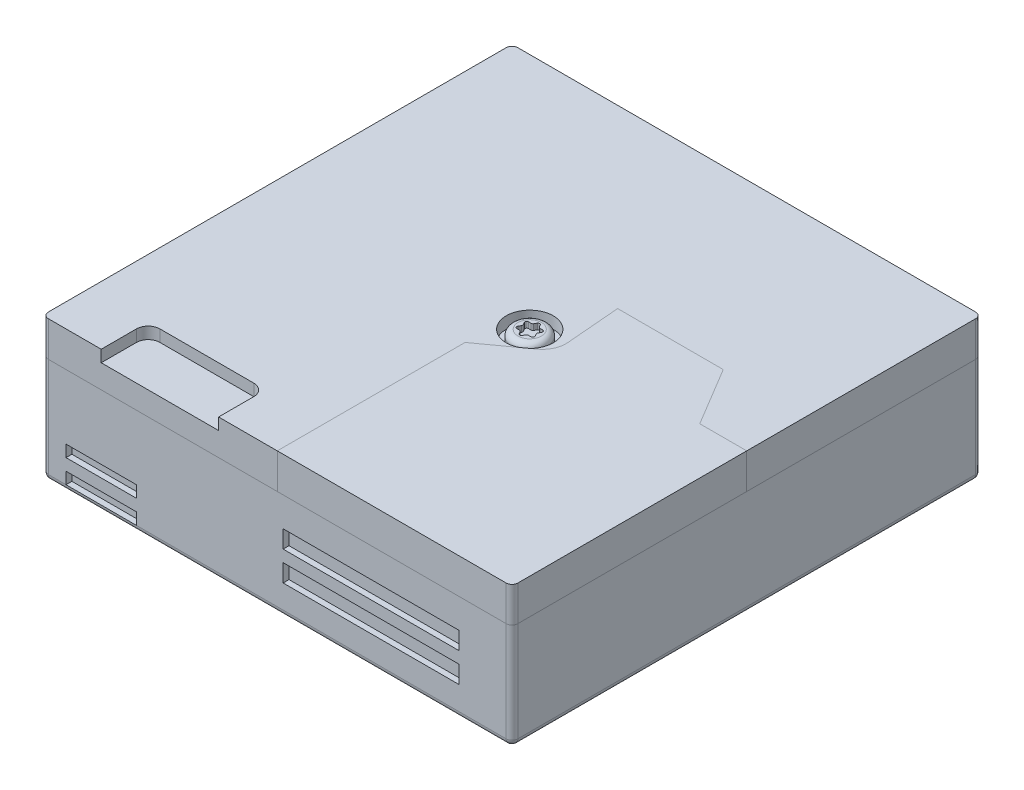
from build123d import *

# Parameters (mm, degrees)
SKETCH1_W           = 40
SKETCH1_H           = 40
BOSS_EXTRUDE1_DEPTH = 9
SKETCH1_2_W         = 40
SKETCH1_2_H         = 40
BOSS_EXTRUDE2_DEPTH = 3
SKETCH2_W           = 10
SKETCH2_H           = 4
CUT_EXTRUDE1_DEPTH  = 4
CUT_EXTRUDE3_DEPTH  = 3
BOSS_EXTRUDE4_DEPTH = 3
SKETCH4_R           = 2
CUT_EXTRUDE4_DEPTH  = 1
SKETCH5_R           = 1.5
BOSS_EXTRUDE6_DEPTH = 1
BOSS_EXTRUDE7_DEPTH = 0.5
FILLET1_R           = 0.5
FILLET2_R           = 0.5
FILLET3_R           = 0.5
FILLET4_R           = 0.5
SKETCH6_W           = 6
SKETCH6_H           = 1
SKETCH6_W_2         = 15
SKETCH6_H_2         = 1.5
CUT_EXTRUDE5_DEPTH  = 0.5


with BuildPart() as part:
    # Sketch1 → Boss-Extrude1 (new body)
    with BuildSketch(Plane(origin=(0, 0, 0), x_dir=(1, 0, 0), z_dir=(0, 1, 0))):
        with Locations((20, 20)):
            Rectangle(SKETCH1_W, SKETCH1_H)
    extrude(amount=-BOSS_EXTRUDE1_DEPTH)

    # Sketch2 → Cut-Extrude1 (cut)
    with BuildSketch(Plane(origin=(0, 0, -40), x_dir=(-1, 0, 0), z_dir=(0, 0, -1))):
        with Locations((-33, -4)):
            Rectangle(SKETCH2_W, SKETCH2_H)
    extrude(amount=-CUT_EXTRUDE1_DEPTH, mode=Mode.SUBTRACT)

    # Fillet3
    fillet3_edges = [part.edges().sort_by_distance(p)[0] for p in [
        (20, -9, 0),
        (40, -9, -20),
        (20, -9, -40),
        (0, -9, -20),
        (40, -4.5, -40),
        (40, -4.5, 0),
        (0, -4.5, 0),
        (0, -4.5, -40),
    ]]
    fillet(fillet3_edges, radius=FILLET3_R)

    # Sketch6 → Cut-Extrude5 (cut)
    with BuildSketch(Plane.XY):
        with Locations((5, -8)):
            Rectangle(SKETCH6_W, SKETCH6_H)
        with Locations((5, -6)):
            Rectangle(SKETCH6_W, SKETCH6_H)
        with Locations((28, -3.25)):
            Rectangle(SKETCH6_W_2, SKETCH6_H_2)
        with Locations((28, -5.75)):
            Rectangle(SKETCH6_W_2, SKETCH6_H_2)
    extrude(amount=-CUT_EXTRUDE5_DEPTH, mode=Mode.SUBTRACT)


with BuildPart() as body_2:
    # Sketch1_2 → Boss-Extrude2 (new body)
    with BuildSketch(Plane(origin=(0, 0, 0), x_dir=(1, 0, 0), z_dir=(0, 1, 0))):
        with Locations((20, 20)):
            Rectangle(SKETCH1_2_W, SKETCH1_2_H)
    extrude(amount=BOSS_EXTRUDE2_DEPTH)

    # Sketch3 → Cut-Extrude3 (cut)
    with BuildSketch(Plane(origin=(0, 3, 0), x_dir=(1, 0, 0), z_dir=(0, 1, 0))):
        with BuildLine():
            Line((20, 0), (40, 0))
            Line((40, 0), (40, 20))
            Line((40, 20), (36, 20))
            Line((36, 20), (33, 25))
            Line((33, 25), (24, 25))
            Line((24, 25), (24.388369501, 20.369543813))
            ThreePointArc((24.388369501, 20.369543813), (24.213026482, 19.368050032), (23.567938987, 18.582176574))
            Line((23.567938987, 18.582176574), (20, 16))
            Line((20, 16), (20, 0))
        make_face()
    extrude(amount=-CUT_EXTRUDE3_DEPTH, mode=Mode.SUBTRACT)

    # Sketch4 → Cut-Extrude4 (cut)
    with BuildSketch(Plane(origin=(0, 3, 0), x_dir=(1, 0, 0), z_dir=(0, 1, 0))):
        with Locations((21.785213292, 19.72637998)):
            Circle(SKETCH4_R)
        with BuildLine():
            Line((5, 0), (15, 0))
            Line((15, 0), (15, 3))
            ThreePointArc((15, 3), (14.707106781, 3.707106781), (14, 4))
            Line((14, 4), (6, 4))
            ThreePointArc((6, 4), (5.292893219, 3.707106781), (5, 3))
            Line((5, 3), (5, 0))
        make_face()
    extrude(amount=-CUT_EXTRUDE4_DEPTH, mode=Mode.SUBTRACT)

    # Fillet2
    fillet2_edges = [body_2.edges().sort_by_distance(p)[0] for p in [
        (0, 1.5, 0),
        (40, 1.5, -40),
        (0, 1.5, -40),
    ]]
    fillet(fillet2_edges, radius=FILLET2_R)


with BuildPart() as body_3:
    # Sketch3_3 → Boss-Extrude4 (new body)
    with BuildSketch(Plane(origin=(0, 3, 0), x_dir=(1, 0, 0), z_dir=(0, 1, 0))):
        with BuildLine():
            Line((20, 0), (40, 0))
            Line((40, 0), (40, 20))
            Line((40, 20), (36, 20))
            Line((36, 20), (33, 25))
            Line((33, 25), (24, 25))
            Line((24, 25), (24.388369501, 20.369543813))
            ThreePointArc((24.388369501, 20.369543813), (24.213026482, 19.368050032), (23.567938987, 18.582176574))
            Line((23.567938987, 18.582176574), (20, 16))
            Line((20, 16), (20, 0))
        make_face()
    extrude(amount=-BOSS_EXTRUDE4_DEPTH)

    # Fillet4
    fillet4_edges = [body_3.edges().sort_by_distance(p)[0] for p in [
        (40, 1.5, 0),
    ]]
    fillet(fillet4_edges, radius=FILLET4_R)


with BuildPart() as body_4:
    # Sketch5 → Boss-Extrude6 (new body)
    with BuildSketch(Plane(origin=(0, 2, 0), x_dir=(1, 0, 0), z_dir=(0, 1, 0))):
        with Locations((21.785213292, 19.72637998)):
            Circle(SKETCH5_R)
        with BuildLine():
            Line((21.409935617, 20.22637998), (21.178995509, 20.22637998))
            ThreePointArc((21.178995509, 20.22637998), (21.049091699, 20.15137998), (21.049091699, 20.00137998))
            Line((21.049091699, 20.00137998), (21.164561753, 19.80137998))
            ThreePointArc((21.164561753, 19.80137998), (21.184657942, 19.72637998), (21.164561753, 19.65137998))
            Line((21.164561753, 19.65137998), (21.049091699, 19.45137998))
            ThreePointArc((21.049091699, 19.45137998), (21.049091699, 19.30137998), (21.178995509, 19.22637998))
            Line((21.178995509, 19.22637998), (21.409935617, 19.22637998))
            ThreePointArc((21.409935617, 19.22637998), (21.484935617, 19.20628379), (21.539839428, 19.15137998))
            Line((21.539839428, 19.15137998), (21.655309481, 18.95137998))
            ThreePointArc((21.655309481, 18.95137998), (21.785213292, 18.87637998), (21.915117103, 18.95137998))
            Line((21.915117103, 18.95137998), (22.030587156, 19.15137998))
            ThreePointArc((22.030587156, 19.15137998), (22.085490967, 19.20628379), (22.160490967, 19.22637998))
            Line((22.160490967, 19.22637998), (22.391431075, 19.22637998))
            ThreePointArc((22.391431075, 19.22637998), (22.521334885, 19.30137998), (22.521334885, 19.45137998))
            Line((22.521334885, 19.45137998), (22.405864831, 19.65137998))
            ThreePointArc((22.405864831, 19.65137998), (22.385768642, 19.72637998), (22.405864831, 19.80137998))
            Line((22.405864831, 19.80137998), (22.521334885, 20.00137998))
            ThreePointArc((22.521334885, 20.00137998), (22.521334885, 20.15137998), (22.391431075, 20.22637998))
            Line((22.391431075, 20.22637998), (22.160490967, 20.22637998))
            ThreePointArc((22.160490967, 20.22637998), (22.085490967, 20.246476169), (22.030587156, 20.30137998))
            Line((22.030587156, 20.30137998), (21.915117103, 20.50137998))
            ThreePointArc((21.915117103, 20.50137998), (21.785213292, 20.57637998), (21.655309481, 20.50137998))
            Line((21.655309481, 20.50137998), (21.539839428, 20.30137998))
            ThreePointArc((21.539839428, 20.30137998), (21.484935617, 20.246476169), (21.409935617, 20.22637998))
        make_face(mode=Mode.SUBTRACT)
    extrude(amount=BOSS_EXTRUDE6_DEPTH)

    # Fillet1
    fillet1_edges = [body_4.edges().sort_by_distance(p)[0] for p in [
        (20.285213292, 3, -19.72637998),
    ]]
    fillet(fillet1_edges, radius=FILLET1_R)


with BuildPart() as body_5:
    # Sketch5_2 → Boss-Extrude7 (new body)
    with BuildSketch(Plane(origin=(0, 2, 0), x_dir=(1, 0, 0), z_dir=(0, 1, 0))):
        with BuildLine():
            ThreePointArc((21.539839428, 20.30137998), (21.484935617, 20.246476169), (21.409935617, 20.22637998))
            Line((21.409935617, 20.22637998), (21.178995509, 20.22637998))
            ThreePointArc((21.178995509, 20.22637998), (21.049091699, 20.15137998), (21.049091699, 20.00137998))
            Line((21.049091699, 20.00137998), (21.164561753, 19.80137998))
            ThreePointArc((21.164561753, 19.80137998), (21.184657942, 19.72637998), (21.164561753, 19.65137998))
            Line((21.164561753, 19.65137998), (21.049091699, 19.45137998))
            ThreePointArc((21.049091699, 19.45137998), (21.049091699, 19.30137998), (21.178995509, 19.22637998))
            Line((21.178995509, 19.22637998), (21.409935617, 19.22637998))
            ThreePointArc((21.409935617, 19.22637998), (21.484935617, 19.20628379), (21.539839428, 19.15137998))
            Line((21.539839428, 19.15137998), (21.655309481, 18.95137998))
            ThreePointArc((21.655309481, 18.95137998), (21.785213292, 18.87637998), (21.915117103, 18.95137998))
            Line((21.915117103, 18.95137998), (22.030587156, 19.15137998))
            ThreePointArc((22.030587156, 19.15137998), (22.085490967, 19.20628379), (22.160490967, 19.22637998))
            Line((22.160490967, 19.22637998), (22.391431075, 19.22637998))
            ThreePointArc((22.391431075, 19.22637998), (22.521334885, 19.30137998), (22.521334885, 19.45137998))
            Line((22.521334885, 19.45137998), (22.405864831, 19.65137998))
            ThreePointArc((22.405864831, 19.65137998), (22.385768642, 19.72637998), (22.405864831, 19.80137998))
            Line((22.405864831, 19.80137998), (22.521334885, 20.00137998))
            ThreePointArc((22.521334885, 20.00137998), (22.521334885, 20.15137998), (22.391431075, 20.22637998))
            Line((22.391431075, 20.22637998), (22.160490967, 20.22637998))
            ThreePointArc((22.160490967, 20.22637998), (22.085490967, 20.246476169), (22.030587156, 20.30137998))
            Line((22.030587156, 20.30137998), (21.915117103, 20.50137998))
            ThreePointArc((21.915117103, 20.50137998), (21.785213292, 20.57637998), (21.655309481, 20.50137998))
            Line((21.655309481, 20.50137998), (21.539839428, 20.30137998))
        make_face()
    extrude(amount=BOSS_EXTRUDE7_DEPTH)


solid = Compound([part.part, body_2.part, body_3.part, body_4.part, body_5.part])
